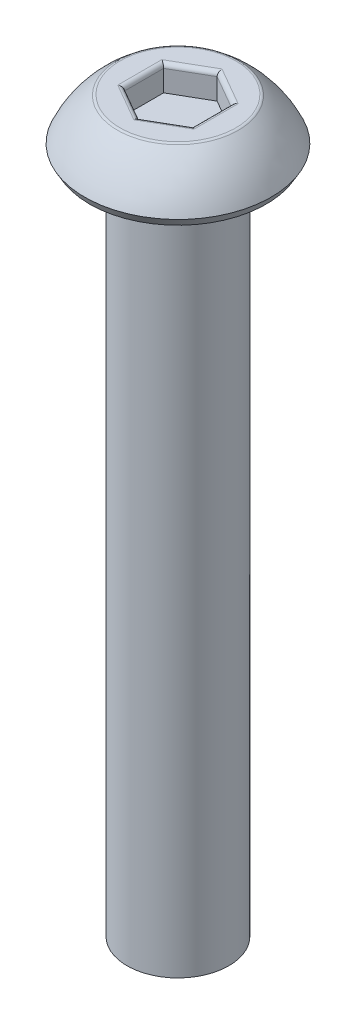
from build123d import *

# Parameters (mm, degrees)
CUT_EXTRUDE1_DEPTH = 0.75
FILLET1_R          = 0.125


with BuildPart() as part:
    # Sketch1 → Revolve1 (revolve)
    with BuildSketch(Plane(origin=(0, 0, 0), x_dir=(0, 0, -1), z_dir=(1, 0, 0))):
        with BuildLine():
            Line((0, 1.5), (-1.75, 1.5))
            ThreePointArc((-1.75, 1.5), (-2.334912942, 0.942930354), (-2.75, 0.25))
            Line((-2.75, 0.25), (-2.605662433, 0))
            Line((-2.605662433, 0), (-1.5, 0))
            Line((-1.5, 0), (-1.5, -20))
            Line((-1.5, -20), (0, -20))
            Line((0, -20), (0, 1.5))
        make_face()
    revolve(axis=Axis((0, -20, 0), (0, 1, 0)))

    # Sketch2 → Cut-Extrude1 (cut)
    with BuildSketch(Plane(origin=(0, 1.5, 0), x_dir=(1, 0, 0), z_dir=(0, 1, 0))):
        Polygon((0, 1.154700538), (-1, 0.577350269), (-1, -0.577350269), (0, -1.154700538), (1, -0.577350269), (1, 0.577350269), align=None)
    extrude(amount=-CUT_EXTRUDE1_DEPTH, mode=Mode.SUBTRACT)

    # Fillet1
    fillet1_edges = [part.edges().sort_by_distance(p)[0] for p in [
        (0.5, 1.5, -0.866025404),
        (-0.5, 1.5, -0.866025404),
        (-1, 1.5, 0),
        (-0.5, 1.5, 0.866025404),
        (0.5, 1.5, 0.866025404),
        (1, 1.5, 0),
        (0, 1.5, -1.75),
    ]]
    fillet(fillet1_edges, radius=FILLET1_R)


solid = part.part
